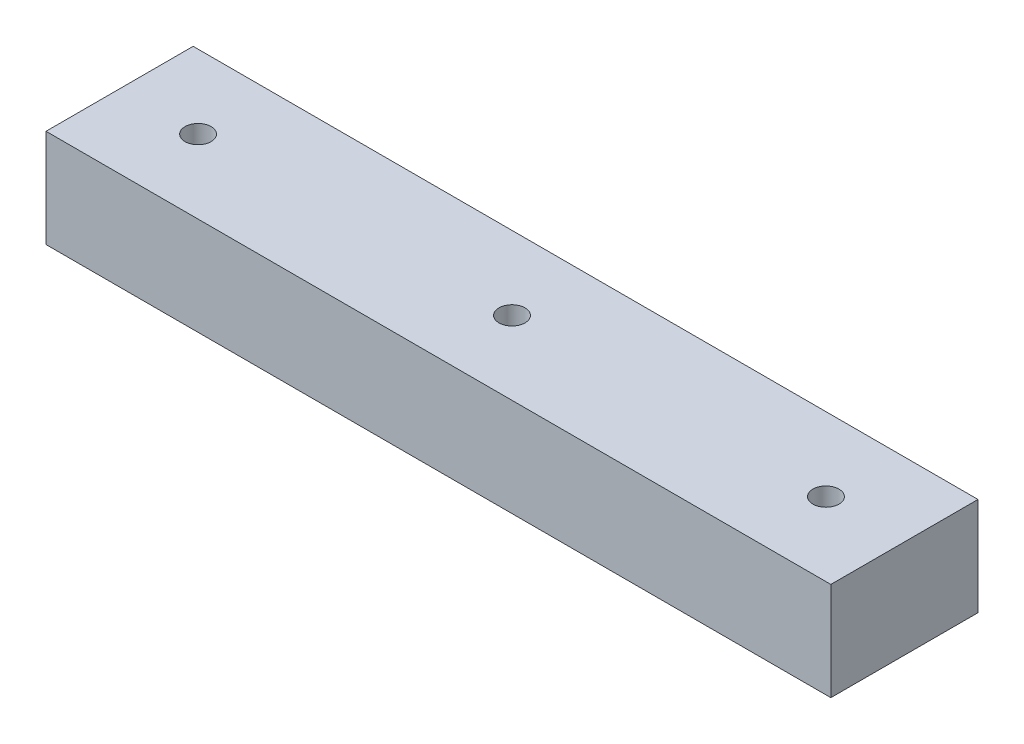
from build123d import *

# Parameters (mm, degrees)
SKETCH1_W           = 203.2
SKETCH1_H           = 38.1
BOSS_EXTRUDE1_DEPTH = 25.4
SKETCH2_R           = 3.3782
CUT_EXTRUDE1_DEPTH  = 26.4


with BuildPart() as part:
    # Sketch1 → Boss-Extrude1 (new body)
    with BuildSketch(Plane(origin=(0, 0, 0), x_dir=(1, 0, 0), z_dir=(0, 1, 0))):
        Rectangle(SKETCH1_W, SKETCH1_H)
    extrude(amount=BOSS_EXTRUDE1_DEPTH)

    # Sketch2 → Cut-Extrude1 (cut, through all)
    with BuildSketch(Plane(origin=(0, 25.4, 0), x_dir=(1, 0, 0), z_dir=(0, 1, 0))):
        Circle(SKETCH2_R)
        with Locations((-81.28, 0)):
            Circle(SKETCH2_R)
        with Locations((81.28, 0)):
            Circle(SKETCH2_R)
    extrude(amount=-CUT_EXTRUDE1_DEPTH, mode=Mode.SUBTRACT)


solid = part.part
